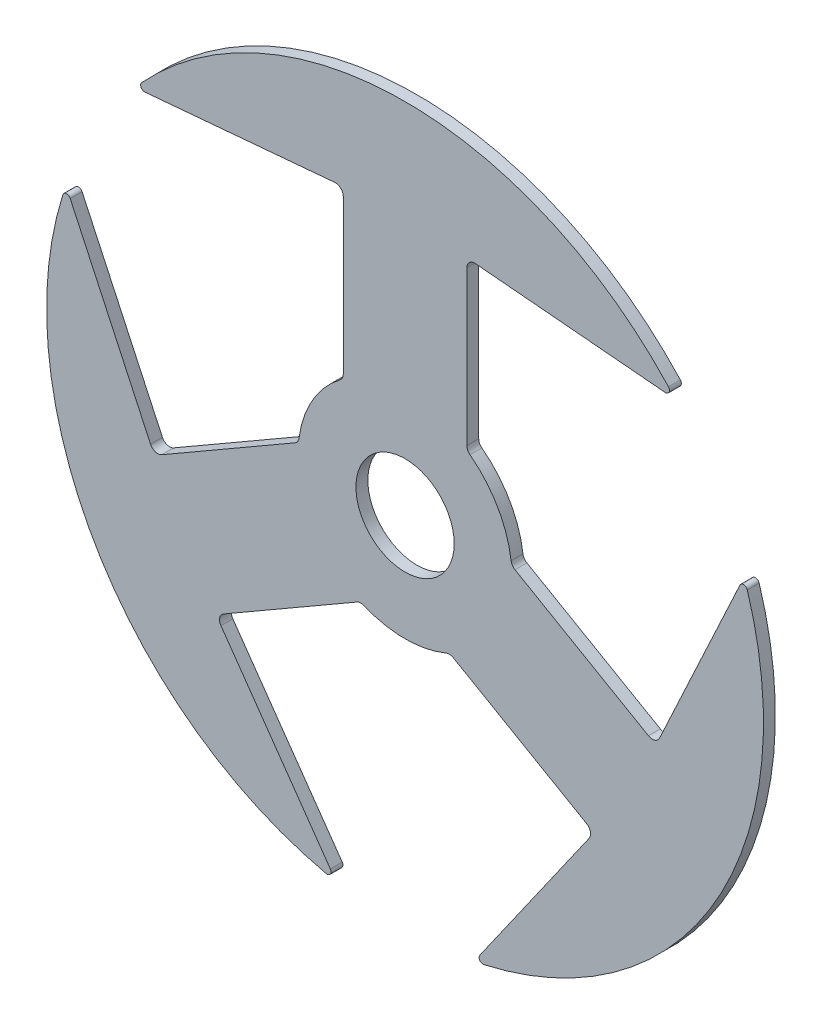
from build123d import *

# Parameters (mm, degrees)
SKETCH1_R           = 1.5748
BOSS_EXTRUDE1_DEPTH = 0.381


with BuildPart() as part:
    # Sketch1 → Boss-Extrude1 (new body)
    with BuildSketch(Plane.XY):
        with BuildLine():
            Line((1.9812, 2.927177815), (1.9812, 7.866528823))
            ThreePointArc((1.9812, 7.866528823), (2.063659626, 8.053851807), (2.257498427, 8.119548151))
            Line((2.257498427, 8.119548151), (8.340740358, 7.583436046))
            ThreePointArc((8.340740358, 7.583436046), (8.465877984, 7.653948909), (8.445206773, 7.796090354))
            ThreePointArc((8.445206773, 7.796090354), (0, 11.4935), (-8.445206773, 7.796090354))
            ThreePointArc((-8.445206773, 7.796090354), (-8.465877984, 7.653948909), (-8.340740358, 7.583436046))
            Line((-8.340740358, 7.583436046), (-2.257498427, 8.119548151))
            ThreePointArc((-2.257498427, 8.119548151), (-2.063659626, 8.053851806), (-1.9812, 7.866528823))
            Line((-1.9812, 7.866528823), (-1.9812, 2.927177815))
            ThreePointArc((-1.9812, 2.927177815), (-2.007526398, 2.814569063), (-2.081048276, 2.725303483))
            ThreePointArc((-2.081048276, 2.725303483), (-2.96960111, 1.7145), (-3.400706187, 0.439588932))
            ThreePointArc((-3.400706187, 0.439588932), (-3.441251508, 0.331284328), (-3.525610349, 0.252180623))
            Line((-3.525610349, 0.252180623), (-7.8032138, -2.217494881))
            ThreePointArc((-7.8032138, -2.217494881), (-8.006670076, -2.239744242), (-8.160484179, -2.104723089))
            Line((-8.160484179, -2.104723089), (-10.737818442, 3.431575013))
            ThreePointArc((-10.737818442, 3.431575013), (-10.861453187, 3.504690945), (-10.974215684, 3.415718428))
            ThreePointArc((-10.974215684, 3.415718428), (-9.953662978, -5.74675), (-2.529008911, -11.211808783))
            ThreePointArc((-2.529008911, -11.211808783), (-2.395575203, -11.158639854), (-2.397078085, -11.015011059))
            Line((-2.397078085, -11.015011059), (-5.902985752, -6.014825062))
            ThreePointArc((-5.902985752, -6.014825062), (-5.94301045, -5.814107564), (-5.8220138, -5.649033941))
            Line((-5.8220138, -5.649033941), (-1.544410349, -3.179358437))
            ThreePointArc((-1.544410349, -3.179358437), (-1.43372511, -3.145853391), (-1.319657911, -3.164892415))
            ThreePointArc((-1.319657911, -3.164892415), (0, -3.429), (1.319657911, -3.164892415))
            ThreePointArc((1.319657911, -3.164892415), (1.43372511, -3.145853391), (1.544410349, -3.179358437))
            Line((1.544410349, -3.179358437), (5.8220138, -5.649033941))
            ThreePointArc((5.8220138, -5.649033941), (5.94301045, -5.814107564), (5.902985752, -6.014825062))
            Line((5.902985752, -6.014825062), (2.397078085, -11.015011059))
            ThreePointArc((2.397078085, -11.015011059), (2.395575203, -11.158639854), (2.529008911, -11.211808783))
            ThreePointArc((2.529008911, -11.211808783), (9.953662978, -5.74675), (10.974215684, 3.415718428))
            ThreePointArc((10.974215684, 3.415718428), (10.861453187, 3.504690945), (10.737818442, 3.431575013))
            Line((10.737818442, 3.431575013), (8.160484179, -2.104723089))
            ThreePointArc((8.160484179, -2.104723089), (8.006670076, -2.239744242), (7.8032138, -2.217494881))
            Line((7.8032138, -2.217494881), (3.525610349, 0.252180623))
            ThreePointArc((3.525610349, 0.252180623), (3.441251508, 0.331284328), (3.400706187, 0.439588932))
            ThreePointArc((3.400706187, 0.439588932), (2.96960111, 1.7145), (2.081048276, 2.725303483))
            ThreePointArc((2.081048276, 2.725303483), (2.007526398, 2.814569063), (1.9812, 2.927177815))
        make_face()
        Circle(SKETCH1_R, mode=Mode.SUBTRACT)
    extrude(amount=BOSS_EXTRUDE1_DEPTH)


solid = part.part
